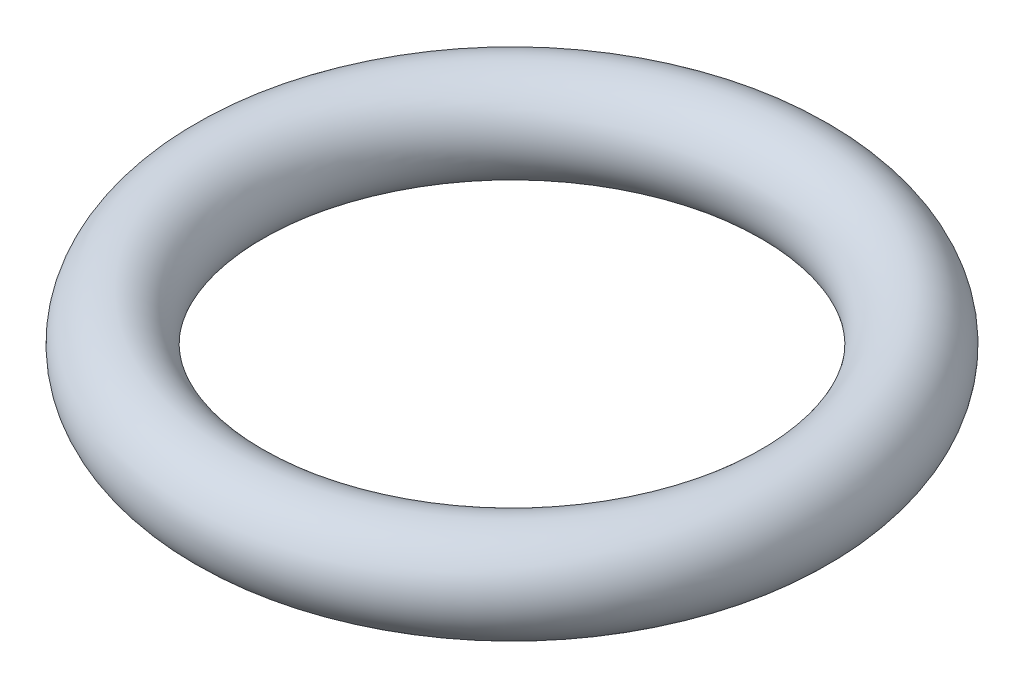
from build123d import *

# Parameters (mm, degrees)
SKETCH2_R = 25.4


with BuildPart() as part:
    # Sketch2 → Revolve1 (revolve)
    with BuildSketch(Plane.XY):
        with Locations((-152.4, 0)):
            Circle(SKETCH2_R)
    revolve(axis=Axis((0, 0, 0), (0, 1, 0)))


solid = part.part
